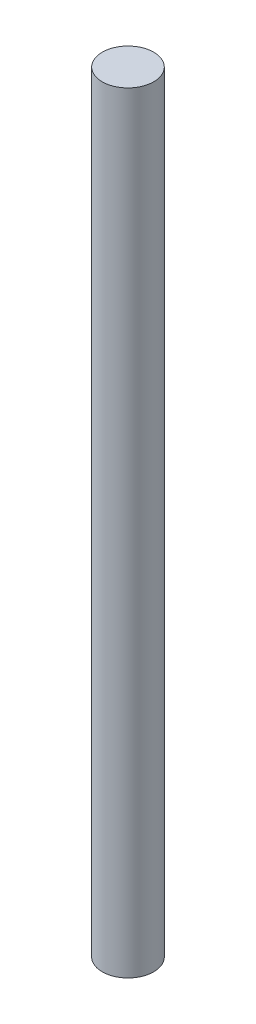
from build123d import *

# Parameters (mm, degrees)
SKETCH1_R           = 3.175
BOSS_EXTRUDE1_DEPTH = 95.25


with BuildPart() as part:
    # Sketch1 → Boss-Extrude1 (new body)
    with BuildSketch(Plane(origin=(0, 0, 0), x_dir=(1, 0, 0), z_dir=(0, 1, 0))):
        Circle(SKETCH1_R)
    extrude(amount=BOSS_EXTRUDE1_DEPTH)


solid = part.part
